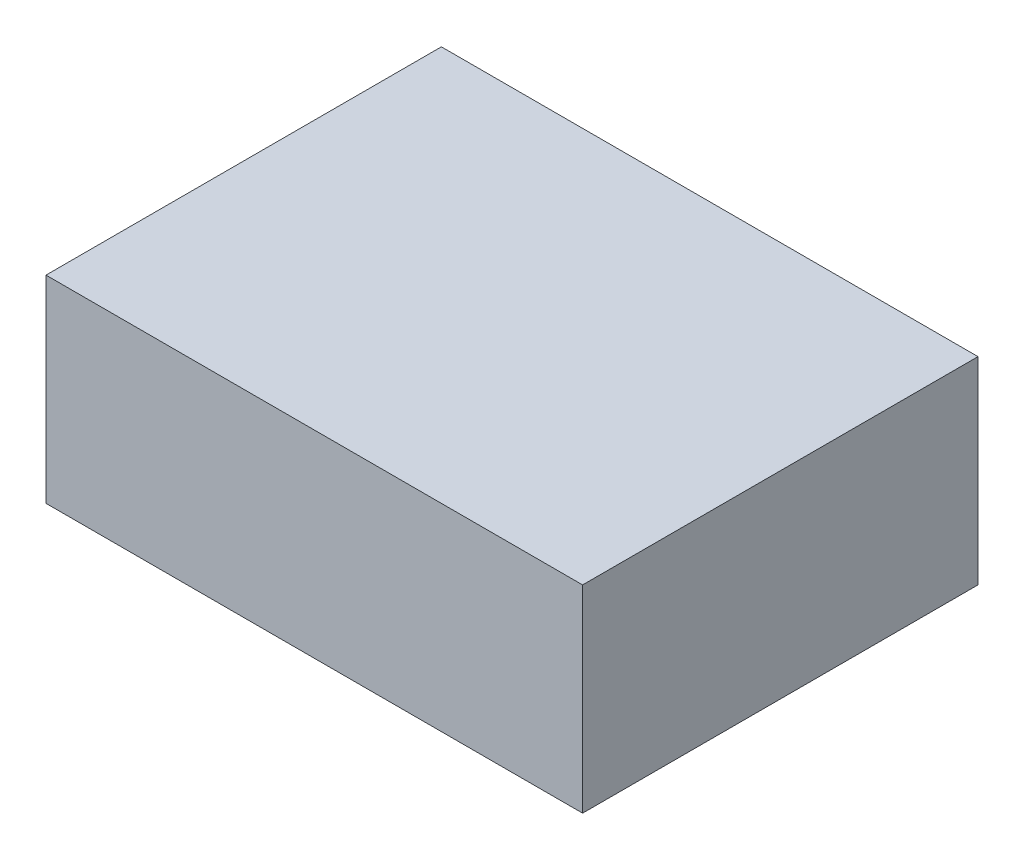
from build123d import *

# Parameters (mm, degrees)
SKETCH1_W           = 95
SKETCH1_H           = 70
BOSS_EXTRUDE1_DEPTH = 35


with BuildPart() as part:
    # Sketch1 → Boss-Extrude1 (new body)
    with BuildSketch(Plane(origin=(0, 0, 0), x_dir=(1, 0, 0), z_dir=(0, 1, 0))):
        Rectangle(SKETCH1_W, SKETCH1_H)
    extrude(amount=BOSS_EXTRUDE1_DEPTH)


solid = part.part
